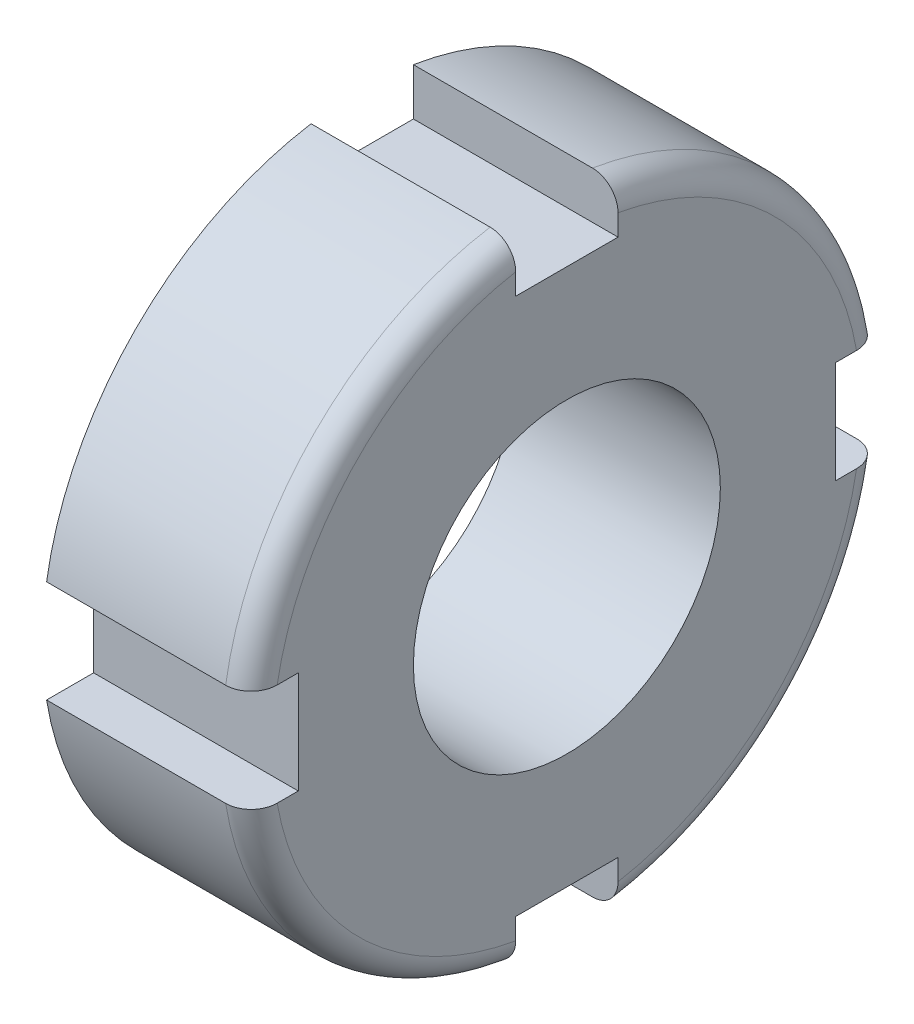
from build123d import *

# Parameters (mm, degrees)
SKETCH1_R           = 12.5
BOSS_EXTRUDE1_DEPTH = 8
SKETCH2_R           = 6
CUT_EXTRUDE1_DEPTH  = 9
FILLET1_R           = 1
SKETCH3_W           = 4
SKETCH3_H           = 4
CUT_EXTRUDE2_DEPTH  = 9
CIRPATTERN1_COUNT   = 4


with BuildPart() as part:
    # Sketch1 → Boss-Extrude1 (new body)
    with BuildSketch(Plane(origin=(0, 0, 0), x_dir=(0, 0, -1), z_dir=(1, 0, 0))):
        Circle(SKETCH1_R)
    extrude(amount=BOSS_EXTRUDE1_DEPTH)

    # Sketch2 → Cut-Extrude1 (cut, through all)
    with BuildSketch(Plane(origin=(8, 0, 0), x_dir=(0, 0, -1), z_dir=(1, 0, 0))):
        Circle(SKETCH2_R)
    extrude(amount=-CUT_EXTRUDE1_DEPTH, mode=Mode.SUBTRACT)

    # Fillet1
    fillet1_edges = [part.edges().sort_by_distance(p)[0] for p in [
        (8, 0, 12.5),
    ]]
    fillet(fillet1_edges, radius=FILLET1_R)

    # Sketch3 → Cut-Extrude2 (cut, through all)
    with BuildSketch(Plane(origin=(8, 0, 0), x_dir=(0, 0, -1), z_dir=(1, 0, 0))):
        with Locations((0, 12.5)):
            Rectangle(SKETCH3_W, SKETCH3_H)
    cut_extrude2 = extrude(amount=-CUT_EXTRUDE2_DEPTH, mode=Mode.SUBTRACT)

    # CirPattern1: Cut-Extrude2 ×4 about axis
    cirpattern1_axis = Axis((0, 0, 0), (1, 0, 0))
    for i in range(1, CIRPATTERN1_COUNT):
        add(cut_extrude2.rotate(cirpattern1_axis, i * 360 / CIRPATTERN1_COUNT), mode=Mode.SUBTRACT)


solid = part.part
